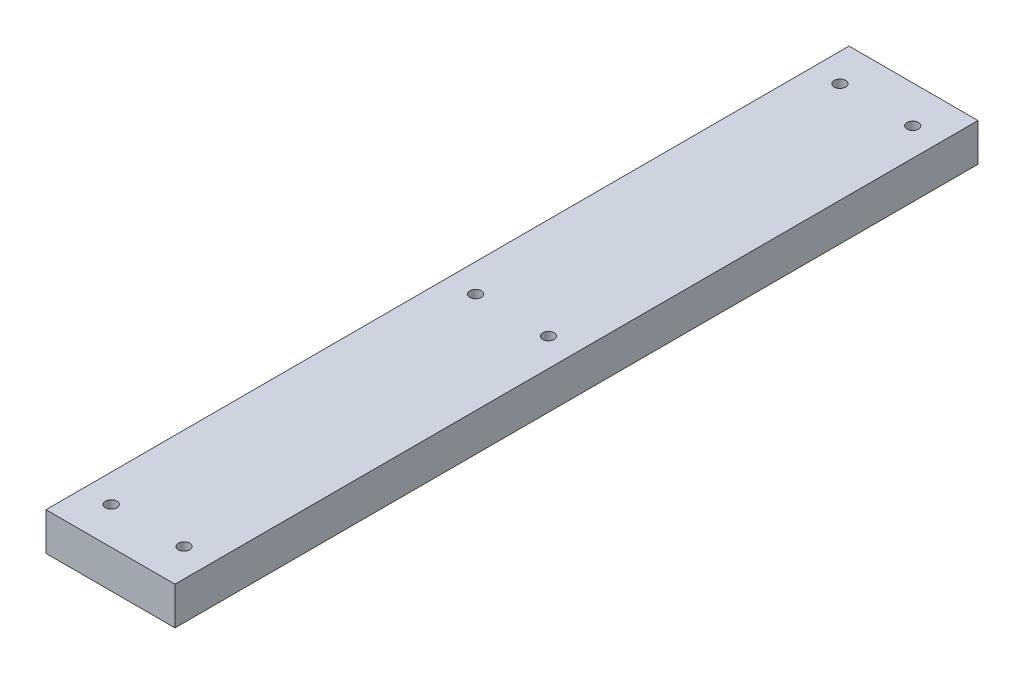
from build123d import *

# Parameters (mm, degrees)
SKETCH1_W                 = 22.225
SKETCH1_H                 = 139.7
BOSS_EXTRUDE1_DEPTH       = 6.604
F_4_40_TAPPED_HOLE1_D     = 2.2606
F_4_40_TAPPED_HOLE1_DEPTH = 7.5946
F_4_40_TAPPED_HOLE1_TIP   = 0.679152758
MOVE_FACE1_BY             = 0.127
MOVE_FACE1_2_BY           = 0.127
MOVE_FACE1_3_BY           = 0.127
MOVE_FACE1_4_BY           = 0.127
MOVE_FACE1_5_BY           = 0.127
MOVE_FACE1_6_BY           = 0.127
MOVE_FACE1_7_BY           = 0.127
MOVE_FACE1_8_BY           = 0.127
MOVE_FACE1_9_BY           = 0.127
MOVE_FACE1_10_BY          = 0.127


with BuildPart() as part:
    # Sketch1 → Boss-Extrude1 (new body)
    with BuildSketch(Plane(origin=(0, 0, 0), x_dir=(1, 0, 0), z_dir=(0, 1, 0))):
        Rectangle(SKETCH1_W, SKETCH1_H)
    extrude(amount=BOSS_EXTRUDE1_DEPTH)

    # #4-40 Tapped Hole1
    with Locations(Plane(origin=(0, 6.604, 0), x_dir=(1, 0, 0), z_dir=(0, 1, 0))):
        with Locations((6.35, 63.5), (6.35, 0), (6.35, -63.5), (-6.35, 63.5), (-6.35, 0), (-6.35, -63.5)):
            Hole(F_4_40_TAPPED_HOLE1_D / 2, depth=F_4_40_TAPPED_HOLE1_DEPTH)
            with Locations((0, 0, -(F_4_40_TAPPED_HOLE1_DEPTH + F_4_40_TAPPED_HOLE1_TIP / 2))):  # 118° drill point
                Cone(0, F_4_40_TAPPED_HOLE1_D / 2, F_4_40_TAPPED_HOLE1_TIP, mode=Mode.SUBTRACT)

    # Move Face1: a face moved outward by 0.127
    extrude(part.faces().sort_by_distance((0, 3.302, 69.85))[0], amount=MOVE_FACE1_BY, dir=(0, 0, 1))

    # Move Face1 2: a curved face moved outward by 0.127
    add(Solid.thicken(part.faces().sort_by_distance((7.4803, 3.302, 0))[0], MOVE_FACE1_2_BY))

    # Move Face1 3: a curved face moved outward by 0.127
    add(Solid.thicken(part.faces().sort_by_distance((-5.2197, 3.302, 0))[0], MOVE_FACE1_3_BY))

    # Move Face1 4: a curved face moved outward by 0.127
    add(Solid.thicken(part.faces().sort_by_distance((7.4803, 3.302, 63.5))[0], MOVE_FACE1_4_BY))

    # Move Face1 5: a curved face moved outward by 0.127
    add(Solid.thicken(part.faces().sort_by_distance((-5.2197, 3.302, 63.5))[0], MOVE_FACE1_5_BY))

    # Move Face1 6: a face moved outward by 0.127
    extrude(part.faces().sort_by_distance((-11.1125, 3.302, 0))[0], amount=MOVE_FACE1_6_BY, dir=(-1, 0, 0))

    # Move Face1 7: a curved face moved outward by 0.127
    add(Solid.thicken(part.faces().sort_by_distance((-5.2197, 3.302, -63.5))[0], MOVE_FACE1_7_BY))

    # Move Face1 8: a curved face moved outward by 0.127
    add(Solid.thicken(part.faces().sort_by_distance((7.4803, 3.302, -63.5))[0], MOVE_FACE1_8_BY))

    # Move Face1 9: a face moved outward by 0.127
    extrude(part.faces().sort_by_distance((0, 3.302, -69.85))[0], amount=MOVE_FACE1_9_BY, dir=(0, 0, -1))

    # Move Face1 10: a face moved outward by 0.127
    extrude(part.faces().sort_by_distance((11.1125, 3.302, 0))[0], amount=MOVE_FACE1_10_BY, dir=(1, 0, 0))


solid = part.part
